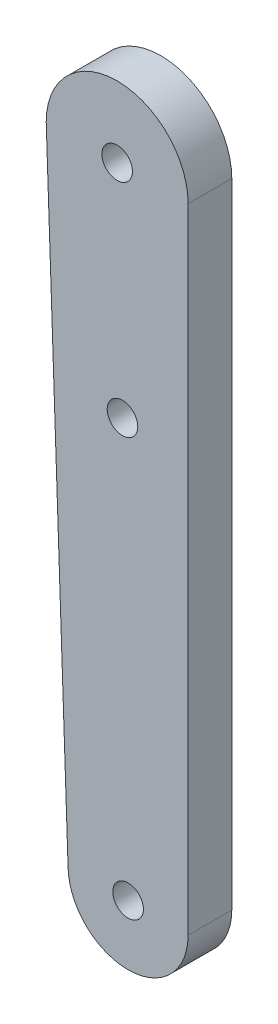
from build123d import *

# Parameters (mm, degrees)
SKETCH1_R           = 1.4
BOSS_EXTRUDE2_DEPTH = 4


with BuildPart() as part:
    # Sketch1 → Boss-Extrude2 (new body)
    with BuildSketch(Plane.XY):
        with BuildLine():
            Line((-0.000688459, 6.993317296), (-0.000688459, 65.016091721))
            ThreePointArc((-0.000688459, 65.016091721), (-6.500688459, 71.516091721), (-13.000688459, 65.016091721))
            Line((-13.000688459, 65.016091721), (-11.000688459, 6.993317296))
            ThreePointArc((-11.000688459, 6.993317296), (-5.500688459, 1.493317296), (-0.000688459, 6.993317296))
        make_face()
        with Locations((-6.500688459, 65.016091721)):
            Circle(SKETCH1_R, mode=Mode.SUBTRACT)
        with Locations((-5.500688459, 6.993317296)):
            Circle(SKETCH1_R, mode=Mode.SUBTRACT)
        with Locations((-6.012756351, 45.016091721)):
            Circle(SKETCH1_R, mode=Mode.SUBTRACT)
    extrude(amount=BOSS_EXTRUDE2_DEPTH)


solid = part.part
